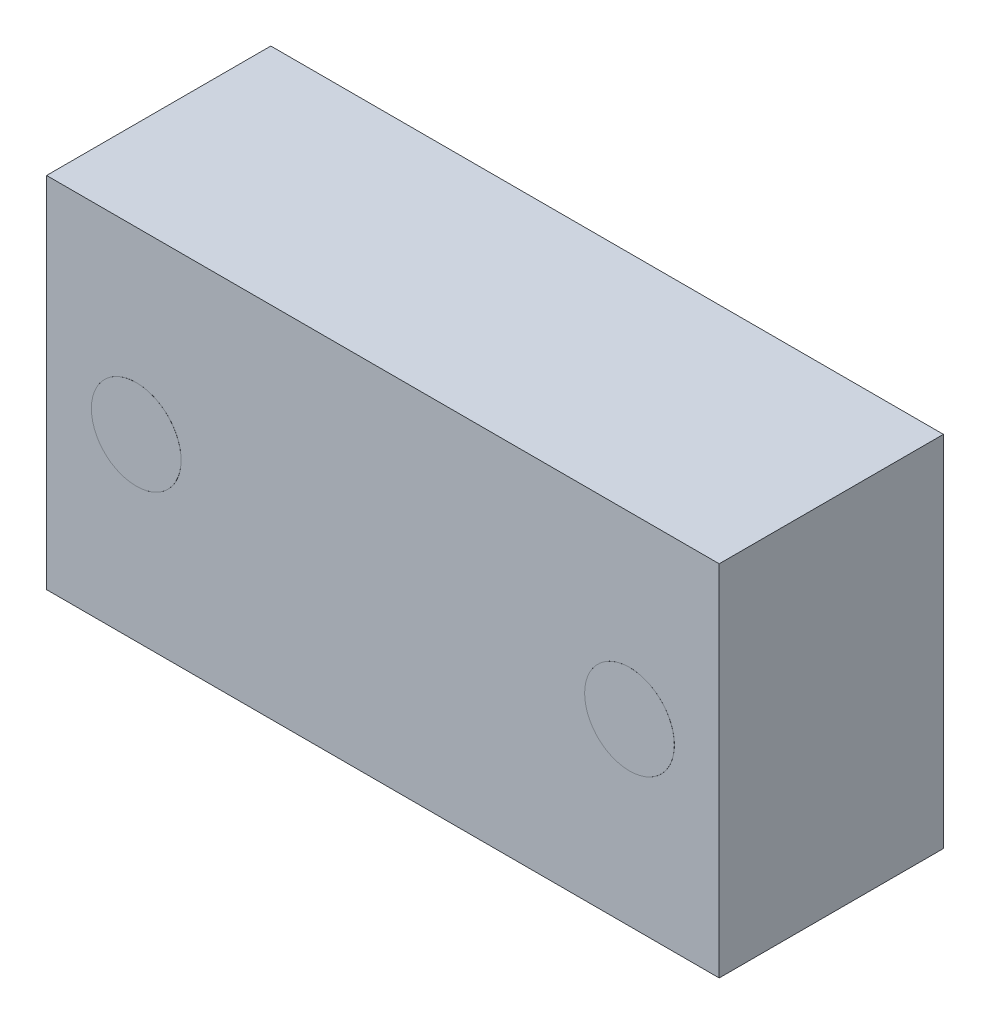
from build123d import *

# Parameters (mm, degrees)
SKETCH1_W           = 15
SKETCH1_H           = 8
BOSS_EXTRUDE1_DEPTH = 5
SKETCH2_R           = 3
BOSS_EXTRUDE2_DEPTH = 0.001
SKETCH3_R           = 1
BOSS_EXTRUDE3_DEPTH = 0.001


with BuildPart() as part:
    # Sketch1 → Boss-Extrude1 (new body)
    with BuildSketch(Plane.XY):
        with Locations((7.5, 4)):
            Rectangle(SKETCH1_W, SKETCH1_H)
    extrude(amount=BOSS_EXTRUDE1_DEPTH)

    # Sketch2 → Boss-Extrude2 (add)
    with BuildSketch(Plane(origin=(0, 0, 0), x_dir=(-1, 0, 0), z_dir=(0, 0, -1))):
        with Locations((-7.5, 4)):
            Circle(SKETCH2_R)
    extrude(amount=BOSS_EXTRUDE2_DEPTH)

    # Sketch3 → Boss-Extrude3 (add)
    with BuildSketch(Plane.XY.offset(5)):
        with Locations((13, 4)):
            Circle(SKETCH3_R)
        with Locations((2, 4)):
            Circle(SKETCH3_R)
    extrude(amount=BOSS_EXTRUDE3_DEPTH)


solid = part.part
